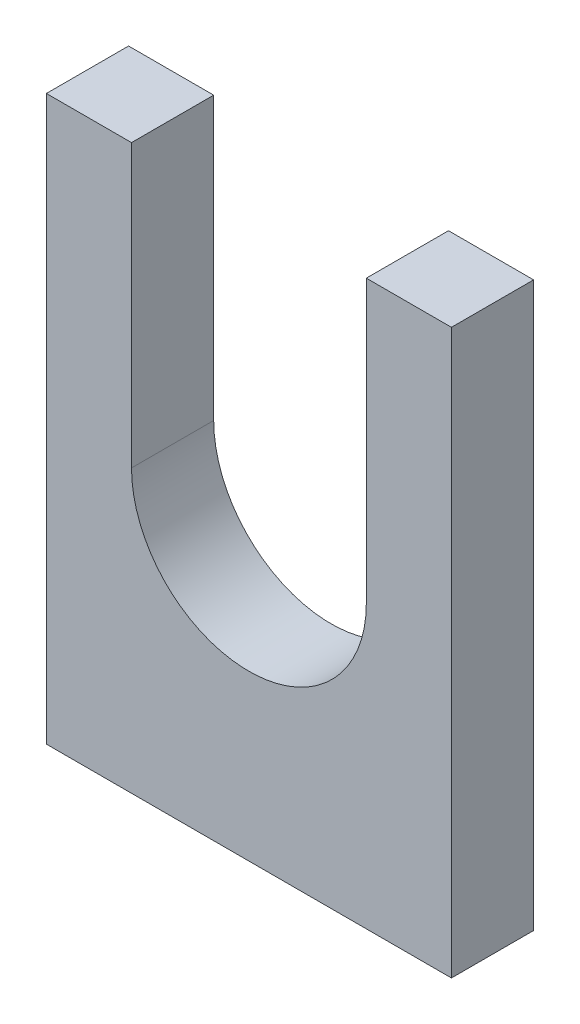
from build123d import *

# Parameters (mm, degrees)
BOSS_EXTRUDE1_DEPTH = 1.75
SCALE1_SCALE        = 25.4


with BuildPart() as part:
    # Sketch1 → Boss-Extrude1 (new body)
    with BuildSketch(Plane.XY):
        with BuildLine():
            Line((0, 12), (0, 0))
            Line((0, 0), (8.625, 0))
            Line((8.625, 0), (8.625, 12))
            Line((8.625, 12), (6.8125, 12))
            Line((6.8125, 12), (6.8125, 6))
            ThreePointArc((6.8125, 6), (4.3125, 3.5), (1.8125, 6))
            Line((1.8125, 6), (1.8125, 12))
            Line((1.8125, 12), (0, 12))
        make_face()
    extrude(amount=BOSS_EXTRUDE1_DEPTH)


with BuildPart() as part_1:
    # Scale1: scaled about (4.3125, 4.750311237, 0.875)
    add(part.part.scale(SCALE1_SCALE).moved(Location((-105.225, -115.907594183, -21.35))))


solid = part_1.part
